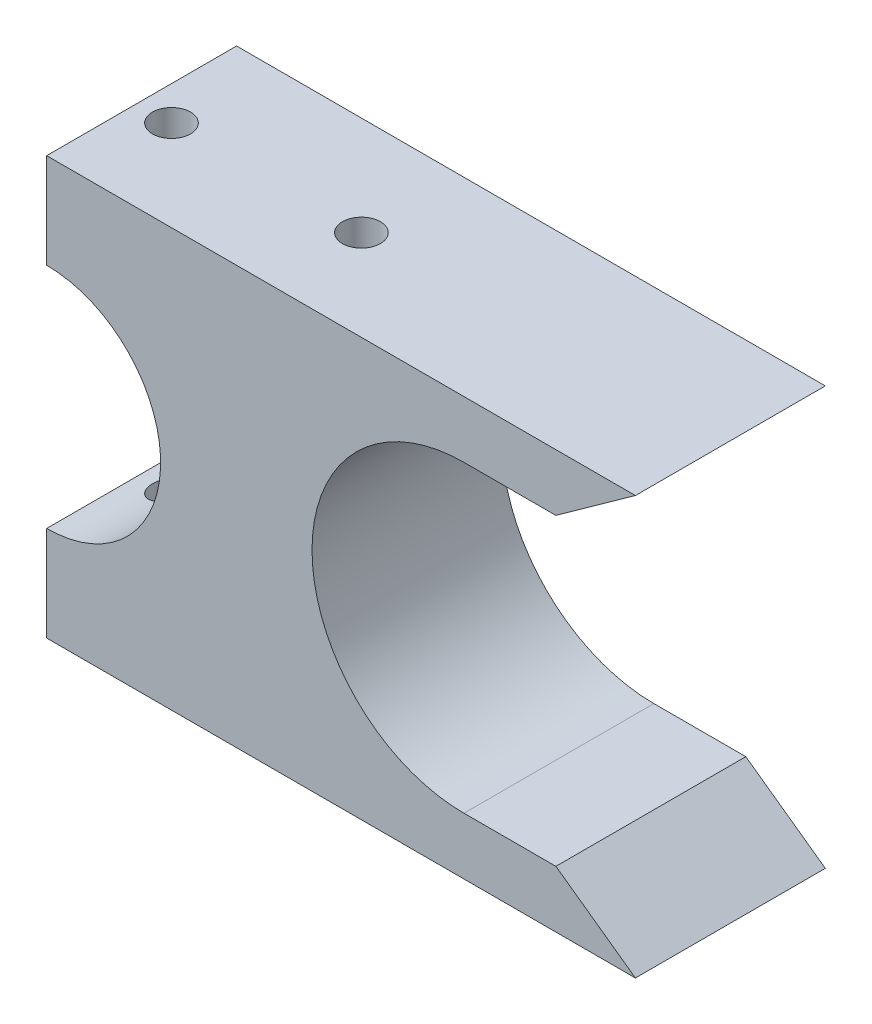
from build123d import *

# Parameters (mm, degrees)
BOSS_EXTRUDE1_DEPTH = 10
SKETCH2_R           = 1
CUT_EXTRUDE1_DEPTH  = 23


with BuildPart() as part:
    # Sketch1 → Boss-Extrude1 (new body)
    with BuildSketch(Plane.XY):
        with BuildLine():
            Line((-13.971915032, 11), (17.028084968, 11))
            Line((17.028084968, 11), (12.841878076, 8))
            Line((12.841878076, 8), (8, 8))
            ThreePointArc((8, 8), (2.343145751, 5.656854249), (0, 0))
            Line((0, 0), (-7.971915032, 0))
            ThreePointArc((-7.971915032, 0), (-9.729274345, 4.242640687), (-13.971915032, 6))
            Line((-13.971915032, 6), (-13.971915032, 11))
        make_face()
    boss_extrude1 = extrude(amount=BOSS_EXTRUDE1_DEPTH)

    # Mirror1: Boss-Extrude1 across plane
    add(boss_extrude1.mirror(Plane.ZX))

    # Sketch2 → Cut-Extrude1 (cut, through all)
    with BuildSketch(Plane(origin=(0, 11, 0), x_dir=(1, 0, 0), z_dir=(0, 1, 0))):
        with Locations((-12.174520537, -5.224275734)):
            Circle(SKETCH2_R)
        with Locations((-2.174520537, -5.224275734)):
            Circle(SKETCH2_R)
    extrude(amount=-CUT_EXTRUDE1_DEPTH, mode=Mode.SUBTRACT)


solid = part.part
